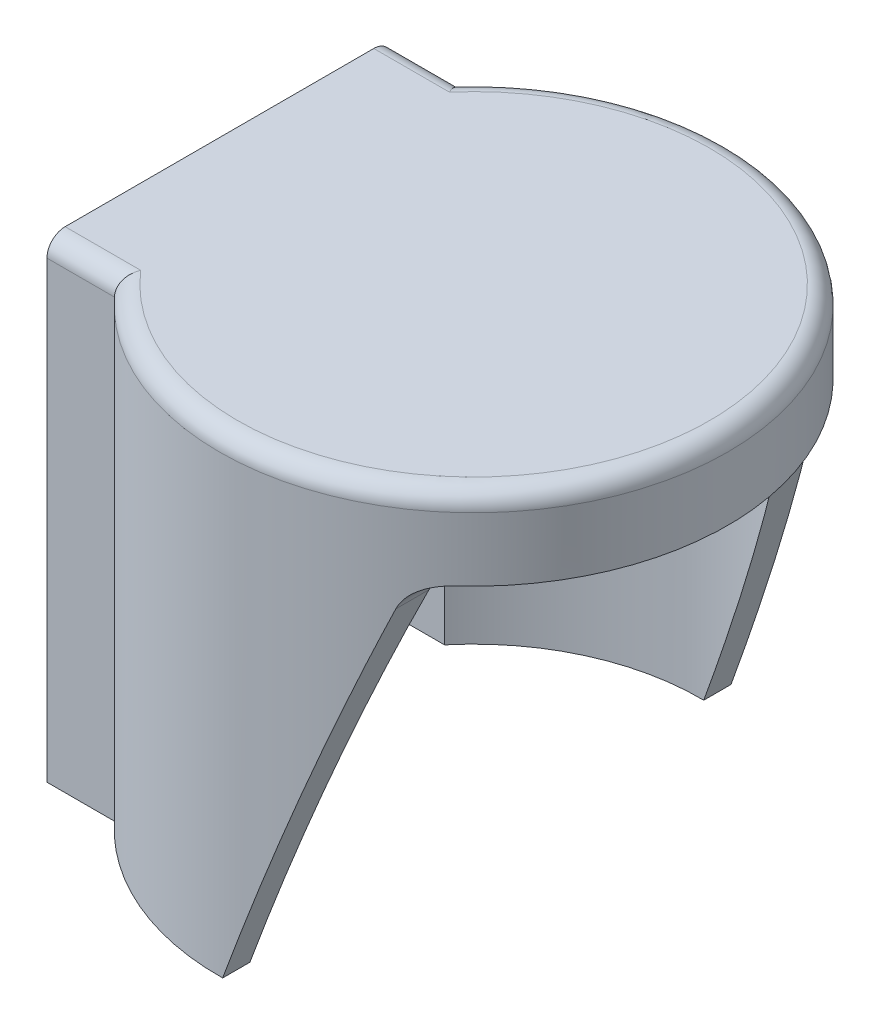
from build123d import *

# Parameters (mm, degrees)
SKETCH1_R               = 14
BOSS_EXTRUDE1_DEPTH     = 26
SKETCH3_W               = 14
SKETCH3_H               = 26
BOSS_EXTRUDE2_DEPTH     = 9.5
SHELL1_T                = -1.5
CUT_EXTRUDE1_DEPTH      = 15
CUT_EXTRUDE1_DEPTH_BACK = 15
FILLET1_R               = 1


with BuildPart() as part:
    # Sketch1 → Boss-Extrude1 (new body)
    with BuildSketch(Plane(origin=(0, 0, 0), x_dir=(1, 0, 0), z_dir=(0, 1, 0))):
        Circle(SKETCH1_R)
    extrude(amount=BOSS_EXTRUDE1_DEPTH)

    # Sketch3 → Boss-Extrude2 (add, symmetric)
    with BuildSketch(Plane.XY):
        with Locations((-7, 13)):
            Rectangle(SKETCH3_W, SKETCH3_H)
    extrude(amount=BOSS_EXTRUDE2_DEPTH, both=True)

    # Shell1
    shell1_openings = [part.faces().sort_by_distance(p)[0] for p in [
        (-6.070870475, 0, 0),
        (-14, 13, 0),
    ]]
    offset(amount=SHELL1_T, openings=shell1_openings, kind=Kind.INTERSECTION)

    # Sketch4 → Cut-Extrude1 (cut, two sides)
    with BuildSketch(Plane.XY) as cut_extrude1_sk:
        with BuildLine():
            Line((0.174639963, 0), (7.521029835, 20.184040287))
            ThreePointArc((7.521029835, 20.184040287), (8.253262204, 21.138304089), (9.400415076, 21.5))
            Line((9.400415076, 21.5), (14, 21.5))
            Line((14, 21.5), (14, 0))
            Line((14, 0), (0.174639963, 0))
        make_face()
    extrude(amount=CUT_EXTRUDE1_DEPTH, mode=Mode.SUBTRACT)
    extrude(cut_extrude1_sk.sketch, amount=-CUT_EXTRUDE1_DEPTH_BACK, mode=Mode.SUBTRACT)

    # Fillet1
    fillet1_edges = [part.edges().sort_by_distance(p)[0] for p in [
        (-12.14174095, 26, 9.5),
        (-12.14174095, 26, -9.5),
        (14, 26, 0),
    ]]
    fillet(fillet1_edges, radius=FILLET1_R)


solid = part.part
